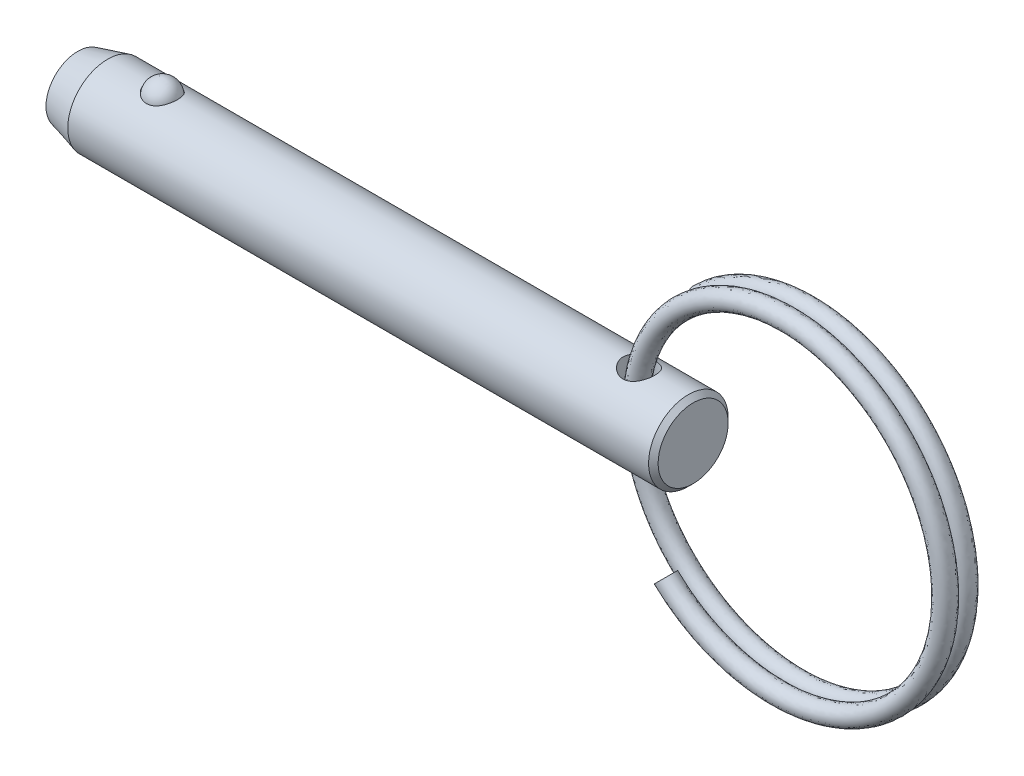
from build123d import *

# Parameters (mm, degrees)
SKETCH4_W          = 1.27
SKETCH4_H          = 6.35
SWEEP1_PITCH       = 1.5494
SWEEP1_HEIGHT      = 1.355725
SWEEP1_RADIUS      = 13.462
SKETCH6_R          = 0.762
SWEEP2_PITCH       = 1.5494
SWEEP2_HEIGHT      = 1.355725
SWEEP2_RADIUS      = 13.462
SWEEP2_START_ANGLE = -180
SKETCH6_2_R        = 0.762


with BuildPart() as part:
    # Sketch1 → Revolve1 (revolve)
    with BuildSketch(Plane.XY):
        Polygon((24.5364, 2.794), (24.1554, 3.175), (-22.166547737, 3.175), (-24.5364, 2.54), (-24.5364, 0), (24.5364, 0), align=None)
    revolve(axis=Axis((24.5364, 0, 0), (1, 0, 0)))

    # Sketch2 → Cut-Revolve1 (revolve, cut)
    with BuildSketch(Plane.XY):
        with BuildLine():
            Line((-16.544582051, 2.8575), (-19.059182051, 2.8575))
            ThreePointArc((-19.059182051, 2.8575), (-17.801882051, 4.1148), (-16.544582051, 2.8575))
        make_face()
    revolve(axis=Axis((-16.544582051, 2.8575, 0), (1, 0, 0)), mode=Mode.SUBTRACT)

    # Sketch4 → Cut-Revolve2 (revolve, cut)
    with BuildSketch(Plane.XY):
        with Locations((20.8534, 0)):
            Rectangle(SKETCH4_W, SKETCH4_H)
    revolve(axis=Axis((20.2184, -3.175, 0), (0, 1, 0)), mode=Mode.SUBTRACT)


with BuildPart() as body_2:
    # Sketch3 → Revolve2 (revolve)
    with BuildSketch(Plane.XY):
        with BuildLine():
            Line((-16.569982051, 2.8575), (-19.033782051, 2.8575))
            ThreePointArc((-19.033782051, 2.8575), (-17.801882051, 4.0894), (-16.569982051, 2.8575))
        make_face()
    revolve(axis=Axis((-16.569982051, 2.8575, 0), (1, 0, 0)))


with BuildPart() as body_3:
    # Sweep1: sweep along a helix
    with BuildLine() as sweep1_path:
        Helix(SWEEP1_PITCH, SWEEP1_HEIGHT, SWEEP1_RADIUS, center=(32.703425091, 0, 0), direction=(0, 0, -1), lefthand=True)
    # Sketch6 → Sweep1 (sweep)
    with BuildSketch(Plane(origin=(114.003847968, 0, 0), x_dir=(0, 0, -1), z_dir=(0, 1, 0))):
        with Locations((0, 94.000422877)):
            Circle(SKETCH6_R)
    sweep(path=sweep1_path.line, is_frenet=True)

    # Sweep2: sweep along a helix
    with BuildLine() as sweep2_path:
        add(Helix(SWEEP2_PITCH, SWEEP2_HEIGHT, SWEEP2_RADIUS, center=(32.703425091, 0, 0), direction=(0, 0, 1), lefthand=True, mode=Mode.PRIVATE).rotate(Axis((32.703425091, 0, 0), (0, 0, 1)), SWEEP2_START_ANGLE))
    # Sketch6_2 → Sweep2 (sweep)
    with BuildSketch(Plane(origin=(114.003847968, 0, 0), x_dir=(0, 0, -1), z_dir=(0, 1, 0))):
        with Locations((0, 94.000422877)):
            Circle(SKETCH6_2_R)
    sweep(path=sweep2_path.line, is_frenet=True)


solid = Compound([part.part, body_2.part, body_3.part])
